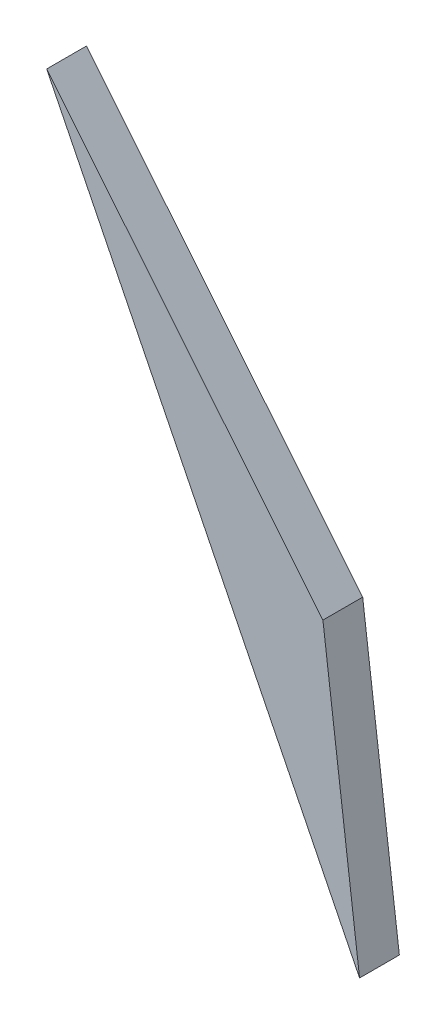
from build123d import *

# Parameters (mm, degrees)
BOSS_EXTRU_1_DEPTH = 3


with BuildPart() as part:
    # Esquisse1 → Boss.-Extru.1 (new body)
    with BuildSketch(Plane.XY):
        Polygon((-0.103997956, -23.227661982), (-2.86929474, -1.227661982), (-23.710295944, 24.358519226), align=None)
    extrude(amount=BOSS_EXTRU_1_DEPTH)


solid = part.part
